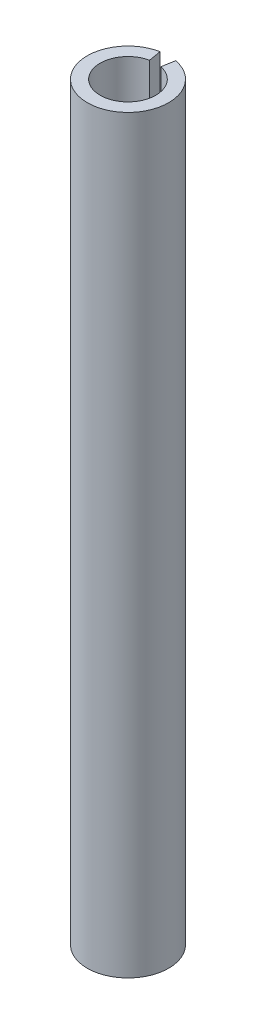
from build123d import *

# Parameters (mm, degrees)
SKETCH1_R               = 9.5
SKETCH1_R_2             = 6.5
BOSS_EXTRUDE1_DEPTH     = 175.02
CUT_EXTRUDE1_DEPTH      = 1
CUT_EXTRUDE1_DEPTH_BACK = 176.02


with BuildPart() as part:
    # Sketch1 → Boss-Extrude1 (new body)
    with BuildSketch(Plane(origin=(0, 0, 0), x_dir=(1, 0, 0), z_dir=(0, 1, 0))):
        Circle(SKETCH1_R)
        Circle(SKETCH1_R_2, mode=Mode.SUBTRACT)
    extrude(amount=BOSS_EXTRUDE1_DEPTH)

    # Sketch2 → Cut-Extrude1 (cut, two sides)
    with BuildSketch(Plane(origin=(0, 175.02, 0), x_dir=(1, 0, 0), z_dir=(0, 1, 0))) as cut_extrude1_sk:
        Polygon((0, 11.5), (-2.2, 11.5), (-1.1, 5.093753049), (1.1, 5.093753049), (2.2, 11.5), align=None)
    extrude(amount=CUT_EXTRUDE1_DEPTH, mode=Mode.SUBTRACT)
    extrude(cut_extrude1_sk.sketch, amount=-CUT_EXTRUDE1_DEPTH_BACK, mode=Mode.SUBTRACT)


solid = part.part
